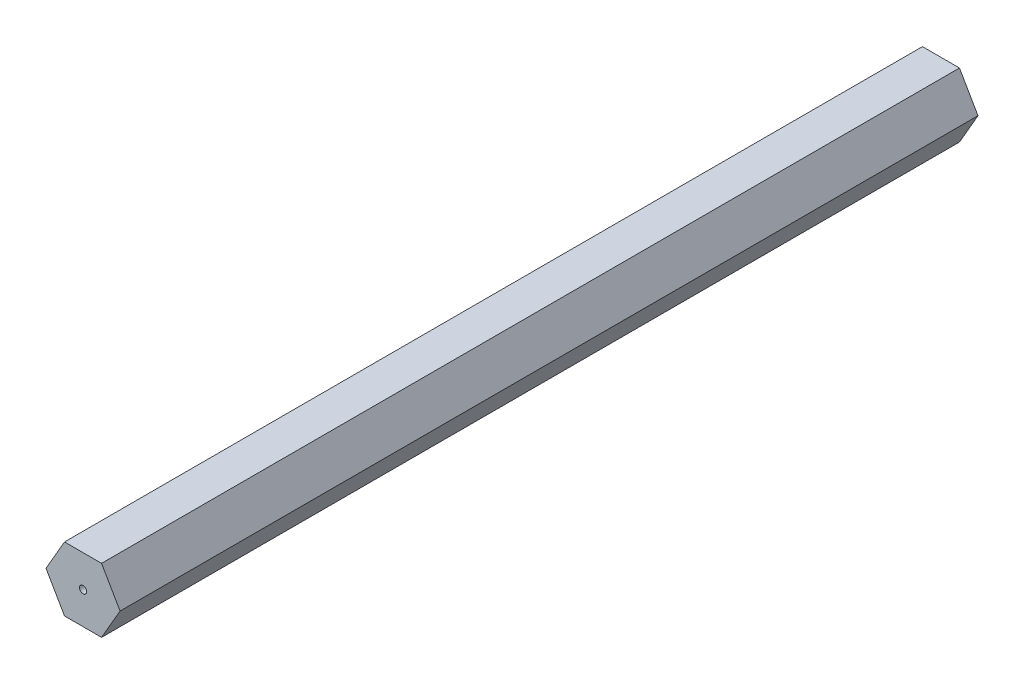
from build123d import *

# Parameters (mm, degrees)
BOSS_EXTRUDE1_DEPTH = 169.8625
SKETCH2_R           = 0.710047413
CUT_EXTRUDE1_DEPTH  = 170.8625


with BuildPart() as part:
    # Sketch1 → Boss-Extrude1 (new body)
    with BuildSketch(Plane.XY):
        Polygon((3.666174209, -6.35), (7.332348419, 0), (3.666174209, 6.35), (-3.666174209, 6.35), (-7.332348419, 0), (-3.666174209, -6.35), align=None)
    extrude(amount=BOSS_EXTRUDE1_DEPTH)

    # Sketch2 → Cut-Extrude1 (cut, through all)
    with BuildSketch(Plane.XY.offset(169.8625)):
        Circle(SKETCH2_R)
    extrude(amount=-CUT_EXTRUDE1_DEPTH, mode=Mode.SUBTRACT)


solid = part.part
